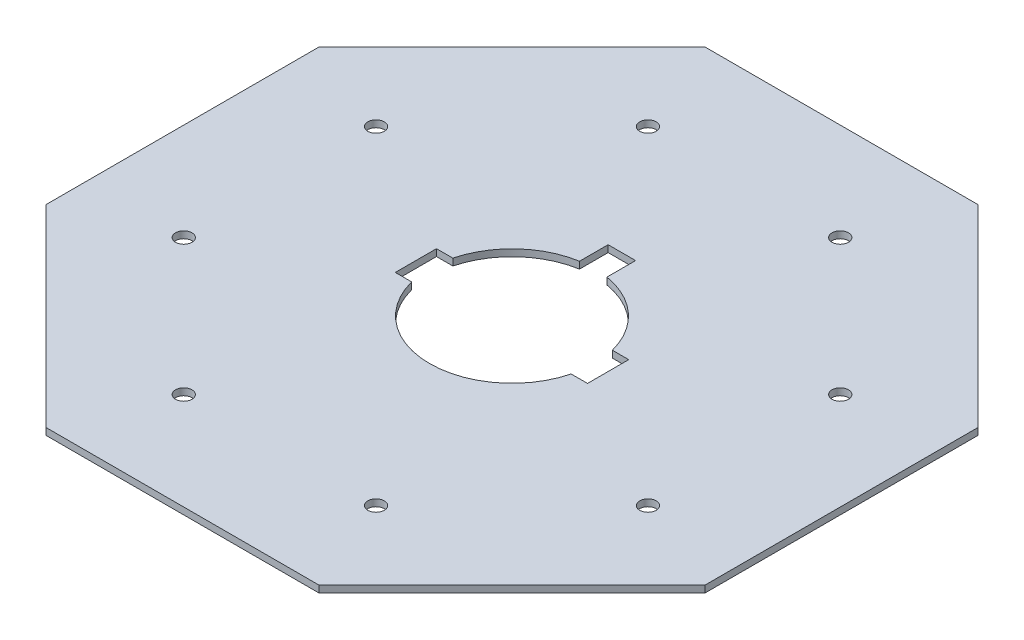
from build123d import *

# Parameters (mm, degrees)
BOSS_EXTRUDE1_DEPTH     = 3.175
SKETCH2_R               = 38.1
CUT_EXTRUDE1_DEPTH      = 1
CUT_EXTRUDE1_DEPTH_BACK = 4.175
SKETCH3_R               = 3.81
CUT_EXTRUDE2_DEPTH      = 4.175
SKETCH4_W               = 12.7
SKETCH4_H               = 19.05
SKETCH4_H_2             = 25.4
CUT_EXTRUDE3_DEPTH      = 4.175


with BuildPart() as part:
    # Sketch1 → Boss-Extrude1 (new body)
    with BuildSketch(Plane(origin=(0, 0, 0), x_dir=(1, 0, 0), z_dir=(0, 1, 0))):
        Polygon((63.126146906, 152.4), (-63.126146906, 152.4), (-152.4, 63.126146906), (-152.4, -63.126146906), (-63.126146906, -152.4), (63.126146906, -152.4), (152.4, -63.126146906), (152.4, 63.126146906), align=None)
    extrude(amount=BOSS_EXTRUDE1_DEPTH)

    # Sketch2 → Cut-Extrude1 (cut, two sides)
    with BuildSketch(Plane(origin=(0, 3.175, 0), x_dir=(1, 0, 0), z_dir=(0, 1, 0))) as cut_extrude1_sk:
        Circle(SKETCH2_R)
    extrude(amount=CUT_EXTRUDE1_DEPTH, mode=Mode.SUBTRACT)
    extrude(cut_extrude1_sk.sketch, amount=-CUT_EXTRUDE1_DEPTH_BACK, mode=Mode.SUBTRACT)

    # Sketch3 → Cut-Extrude2 (cut, through all)
    with BuildSketch(Plane(origin=(0, 3.175, 0), x_dir=(1, 0, 0), z_dir=(0, 1, 0))):
        with Locations((44.463441276, -107.344242958)):
            Circle(SKETCH3_R)
        with Locations((-44.463441276, -107.344242958)):
            Circle(SKETCH3_R)
        with Locations((-107.344242958, -44.463441276)):
            Circle(SKETCH3_R)
        with Locations((-107.344242958, 44.463441276)):
            Circle(SKETCH3_R)
        with Locations((-44.463441276, 107.344242958)):
            Circle(SKETCH3_R)
        with Locations((44.463441276, 107.344242958)):
            Circle(SKETCH3_R)
        with Locations((107.344242958, 44.463441276)):
            Circle(SKETCH3_R)
        with Locations((107.344242958, -44.463441276)):
            Circle(SKETCH3_R)
    extrude(amount=-CUT_EXTRUDE2_DEPTH, mode=Mode.SUBTRACT)

    # Sketch4 → Cut-Extrude3 (cut, through all)
    with BuildSketch(Plane(origin=(0, 3.175, 0), x_dir=(1, 0, 0), z_dir=(0, 1, 0))):
        with Locations((-38.1, 0)):
            Rectangle(SKETCH4_W, SKETCH4_H)
        with Locations((38.1, 0)):
            Rectangle(SKETCH4_W, SKETCH4_H)
        with Locations((0, 38.1)):
            Rectangle(SKETCH4_W, SKETCH4_H_2)
    extrude(amount=-CUT_EXTRUDE3_DEPTH, mode=Mode.SUBTRACT)


solid = part.part
